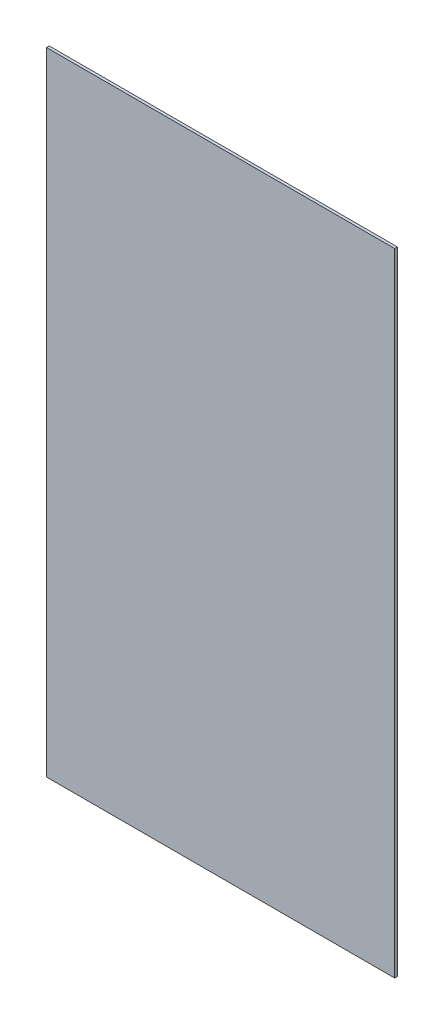
from build123d import *

# Parameters (mm, degrees)
SKETCH1_W      = 603.25
SKETCH1_H      = 1095.375
EXTRUDE1_DEPTH = 4.7625


with BuildPart() as part:
    # Sketch1 → Extrude1 (new body)
    with BuildSketch(Plane.XY):
        with Locations((266.7, 547.6875)):
            Rectangle(SKETCH1_W, SKETCH1_H)
    extrude(amount=EXTRUDE1_DEPTH)


solid = part.part
